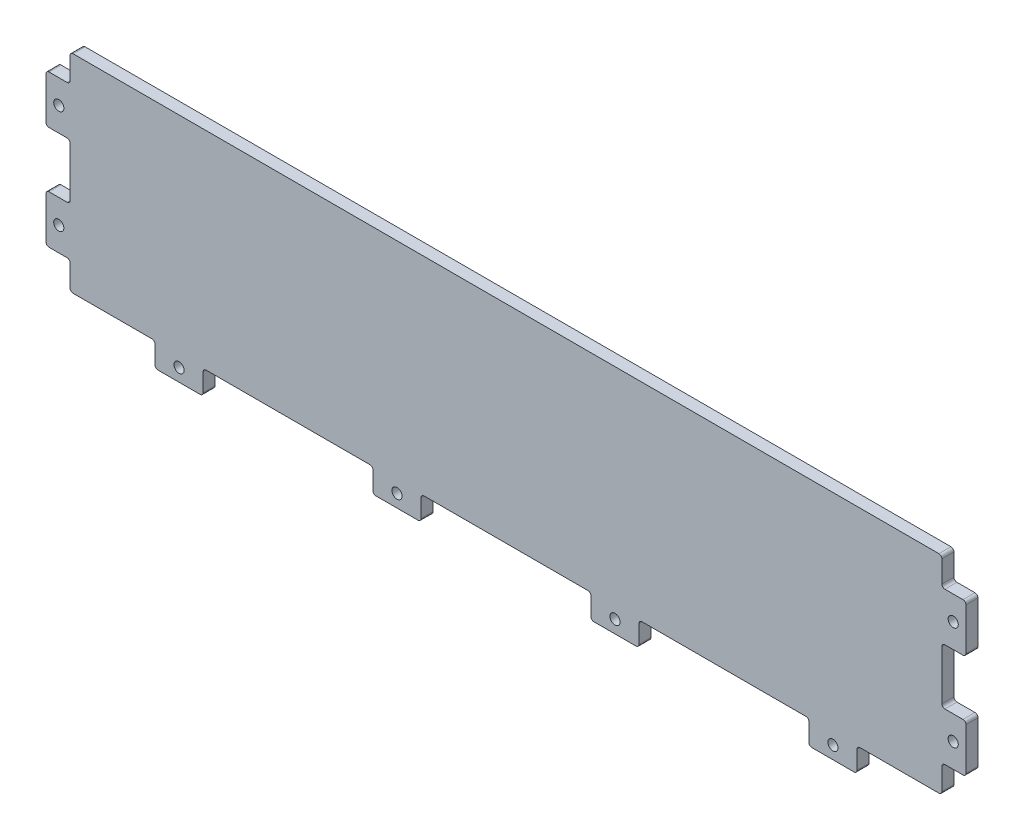
from build123d import *

# Parameters (mm, degrees)
BOSS_EXTRUDE1_DEPTH  = 6.35
TABS_DEPTH           = 6.35
FILLET1_R            = 3.175
SKETCH3_R            = 5.3578125
CABLE_TIE_HOLE_DEPTH = 7.35


with BuildPart() as part:
    # Sketch1 → Boss-Extrude1 (new body, symmetric)
    with BuildSketch(Plane.XY):
        with BuildLine():
            Line((-457.2, -109.5375), (457.2, -109.5375))
            ThreePointArc((457.2, -109.5375), (459.44506403, -108.60756403), (460.375, -106.3625))
            Line((460.375, -106.3625), (460.375, 106.3625))
            ThreePointArc((460.375, 106.3625), (459.44506403, 108.60756403), (457.2, 109.5375))
            Line((457.2, 109.5375), (-457.2, 109.5375))
            ThreePointArc((-457.2, 109.5375), (-459.44506403, 108.60756403), (-460.375, 106.3625))
            Line((-460.375, 106.3625), (-460.375, -106.3625))
            ThreePointArc((-460.375, -106.3625), (-459.44506403, -108.60756403), (-457.2, -109.5375))
        make_face()
    extrude(amount=BOSS_EXTRUDE1_DEPTH, both=True)

    # Sketch2 → Tabs (add, symmetric)
    with BuildSketch(Plane.XY):
        with BuildLine():
            Line((-460.375, 80.16875), (-482.6, 80.16875))
            ThreePointArc((-482.6, 80.16875), (-484.84506403, 79.23881403), (-485.775, 76.99375))
            Line((-485.775, 76.99375), (-485.775, 32.54375))
            ThreePointArc((-485.775, 32.54375), (-484.84506403, 30.29868597), (-482.6, 29.36875))
            Line((-482.6, 29.36875), (-460.375, 29.36875))
            Line((-460.375, 29.36875), (-460.375, 80.16875))
        make_face()
        with BuildLine():
            Line((-460.375, -29.36875), (-482.6, -29.36875))
            ThreePointArc((-482.6, -29.36875), (-484.84506403, -30.29868597), (-485.775, -32.54375))
            Line((-485.775, -32.54375), (-485.775, -76.99375))
            ThreePointArc((-485.775, -76.99375), (-484.84506403, -79.23881403), (-482.6, -80.16875))
            Line((-482.6, -80.16875), (-460.375, -80.16875))
            Line((-460.375, -80.16875), (-460.375, -29.36875))
        make_face()
        with BuildLine():
            Line((-370.68125, -109.5375), (-370.68125, -131.7625))
            ThreePointArc((-370.68125, -131.7625), (-369.75131403, -134.00756403), (-367.50625, -134.9375))
            Line((-367.50625, -134.9375), (-323.05625, -134.9375))
            ThreePointArc((-323.05625, -134.9375), (-320.81118597, -134.00756403), (-319.88125, -131.7625))
            Line((-319.88125, -131.7625), (-319.88125, -109.5375))
            Line((-319.88125, -109.5375), (-370.68125, -109.5375))
        make_face()
        with BuildLine():
            Line((-140.49375, -109.5375), (-140.49375, -131.7625))
            ThreePointArc((-140.49375, -131.7625), (-139.56381403, -134.00756403), (-137.31875, -134.9375))
            Line((-137.31875, -134.9375), (-92.86875, -134.9375))
            ThreePointArc((-92.86875, -134.9375), (-90.62368597, -134.00756403), (-89.69375, -131.7625))
            Line((-89.69375, -131.7625), (-89.69375, -109.5375))
            Line((-89.69375, -109.5375), (-140.49375, -109.5375))
        make_face()
    tabs = extrude(amount=TABS_DEPTH, both=True)

    # Mirror1: Tabs across plane
    add(tabs.mirror(Plane(origin=(0, 0, 0), x_dir=(0, 0, 1), z_dir=(1, 0, 0))))

    # Fillet1
    fillet1_edges = [part.edges().sort_by_distance(p)[0] for p in [
        (460.375, -29.36875, 0),
        (460.375, -80.16875, 0),
        (370.68125, -109.5375, 0),
        (319.88125, -109.5375, 0),
        (140.49375, -109.5375, 0),
        (89.69375, -109.5375, 0),
        (-460.375, 29.36875, 0),
        (-460.375, 80.16875, 0),
        (-460.375, -80.16875, 0),
        (-460.375, -29.36875, 0),
        (-319.88125, -109.5375, 0),
        (-370.68125, -109.5375, 0),
        (-89.69375, -109.5375, 0),
        (-140.49375, -109.5375, 0),
        (460.375, 80.16875, 0),
        (460.375, 29.36875, 0),
    ]]
    fillet(fillet1_edges, radius=FILLET1_R)

    # Sketch3 → Cable Tie hole (cut, symmetric)
    with BuildSketch(Plane.XY):
        with Locations((-472.28125, 54.76875)):
            Circle(SKETCH3_R)
        with Locations((-472.28125, -54.76875)):
            Circle(SKETCH3_R)
        with Locations((-345.28125, -121.44375)):
            Circle(SKETCH3_R)
        with Locations((-115.09375, -121.44375)):
            Circle(SKETCH3_R)
    cable_tie_hole = extrude(amount=CABLE_TIE_HOLE_DEPTH, both=True, mode=Mode.SUBTRACT)

    # Mirror2: Cable Tie hole across plane
    add(cable_tie_hole.mirror(Plane(origin=(0, 0, 0), x_dir=(0, 0, 1), z_dir=(1, 0, 0))), mode=Mode.SUBTRACT)


solid = part.part
